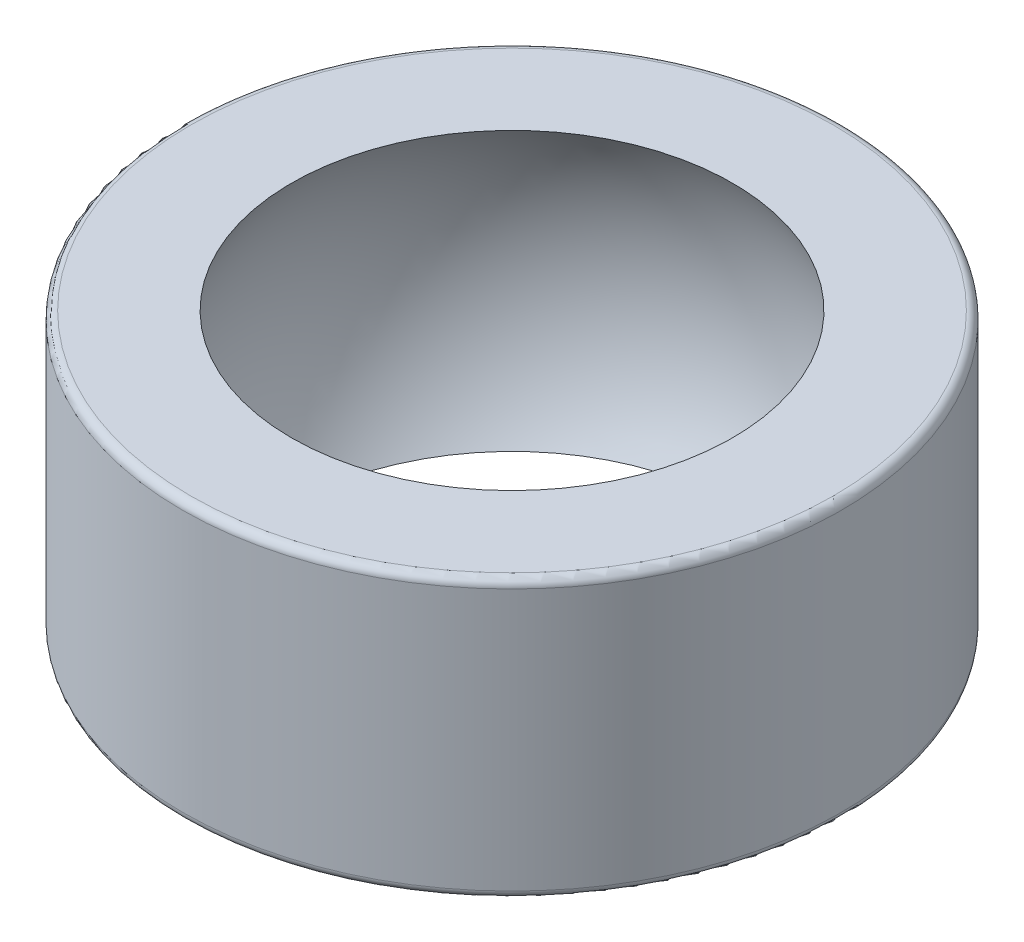
from build123d import *

# Parameters (mm, degrees)
SZKIC1_R                    = 8
DODANIE_WYCI_GNI_CIE1_DEPTH = 3.375
ZAOKR_GLENIE1_R             = 0.2


with BuildPart() as part:
    # Szkic1 → Dodanie-wyciągnięcie1 (new body, symmetric)
    with BuildSketch(Plane(origin=(0, 0, 0), x_dir=(1, 0, 0), z_dir=(0, 1, 0))):
        Circle(SZKIC1_R)
    extrude(amount=DODANIE_WYCI_GNI_CIE1_DEPTH, both=True)

    # Szkic3 → Wycięcie-obrót1 (revolve, cut)
    with BuildSketch(Plane.XY):
        with BuildLine():
            Line((0, -6.33), (0, 6.33))
            ThreePointArc((0, 6.33), (6.33, 0), (0, -6.33))
        make_face()
    revolve(axis=Axis((0, -6.33, 0), (0, 1, 0)), mode=Mode.SUBTRACT)

    # Zaokrąglenie1
    zaokr_glenie1_edges = [part.edges().sort_by_distance(p)[0] for p in [
        (-8, -3.375, 0),
        (-8, 3.375, 0),
    ]]
    fillet(zaokr_glenie1_edges, radius=ZAOKR_GLENIE1_R)


solid = part.part
